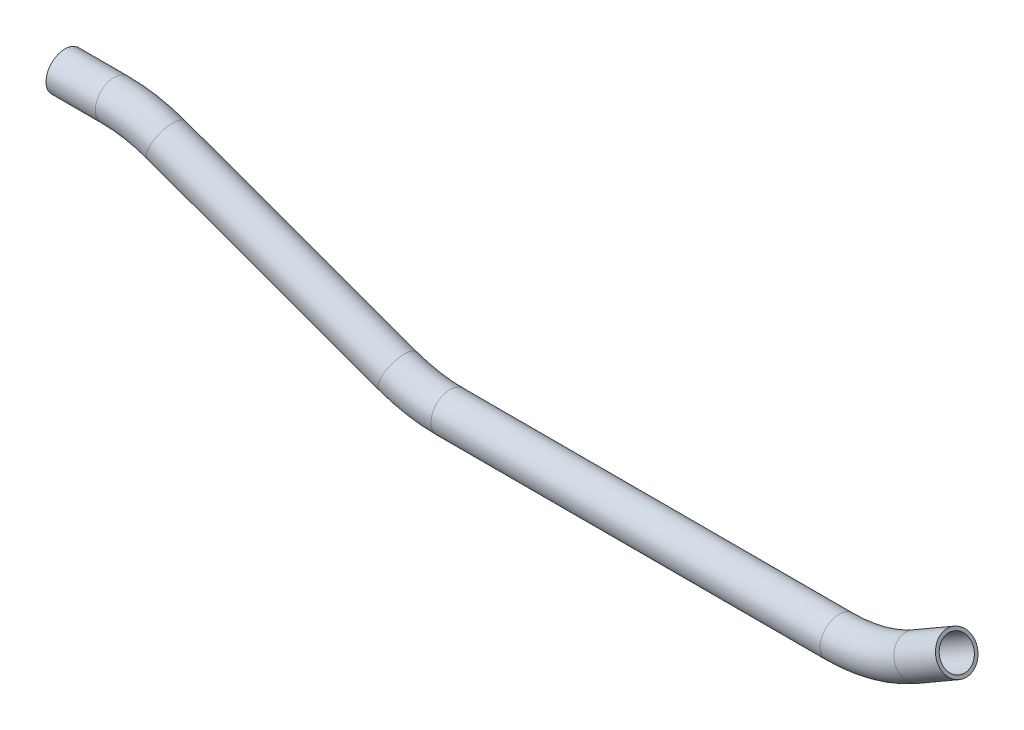
from build123d import *

# Parameters (mm, degrees)
SKETCH2_R   = 9.525
SKETCH2_R_2 = 7.874


with BuildPart() as part:
    # Sweep1: sweep along a path in Sketch1
    with BuildLine(Plane.XY) as sweep1_path:
        Line((-82.715438584, 8.125207387), (-58.051554514, 8.125207387))
        ThreePointArc((-58.051554514, 8.125207387), (-44.819563376, 6.967558166), (-31.989619593, 3.529785091))
        Line((-31.989619593, 3.529785091), (83.882345193, -38.644161077))
        ThreePointArc((83.882345193, -38.644161077), (96.712288976, -42.081934153), (109.944280114, -43.239583374))
        Line((109.944280114, -43.239583374), (304.690435721, -43.239583374))
        ThreePointArc((304.690435721, -43.239583374), (324.412446958, -40.643131337), (342.790435721, -33.030719142))
        Line((342.790435721, -33.030719142), (363.602993383, -21.014583374))
    # Sketch2 → Sweep1 (sweep)
    with BuildSketch(Plane(origin=(-82.715438584, 8.125207387, 0), x_dir=(0, 0, -1), z_dir=(1, 0, 0))):
        Circle(SKETCH2_R)
        Circle(SKETCH2_R_2, mode=Mode.SUBTRACT)
    sweep(path=sweep1_path.line)


solid = part.part
